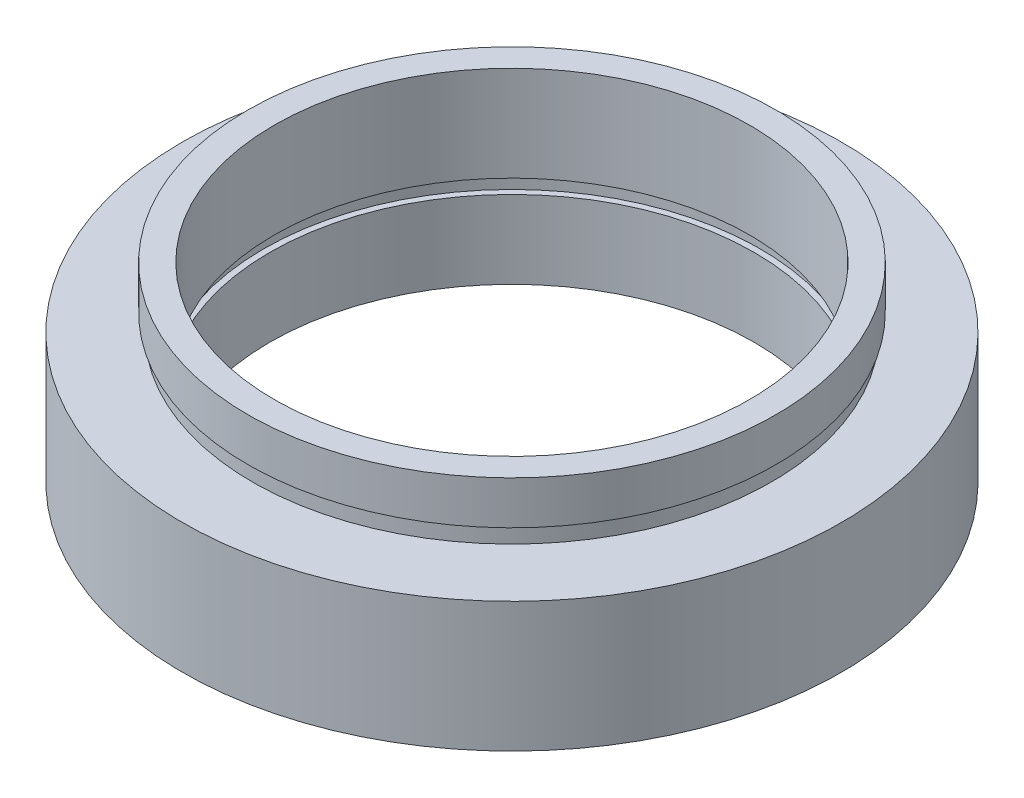
from build123d import *


with BuildPart() as part:
    # 草图1 → 旋转1 (revolve)
    with BuildSketch(Plane.XY, mode=Mode.PRIVATE) as revolve_1_sk:
        Polygon((14, 0), (14, 4.5), (14.35, 4.5), (14.35, 5.5), (13.74, 5.5), (13.74, 11), (15.26, 11), (15.26, 8.5), (15, 8.5), (15, 7.5), (19.05, 7.5), (19.05, 0), align=None)
    revolve(revolve_1_sk.sketch.rotate(Axis((0, 16.886018237, 0), (0, -1, 0)), 180), axis=Axis((0, 16.886018237, 0), (0, -1, 0)))  # turned: the seam where the file's is


solid = part.part
